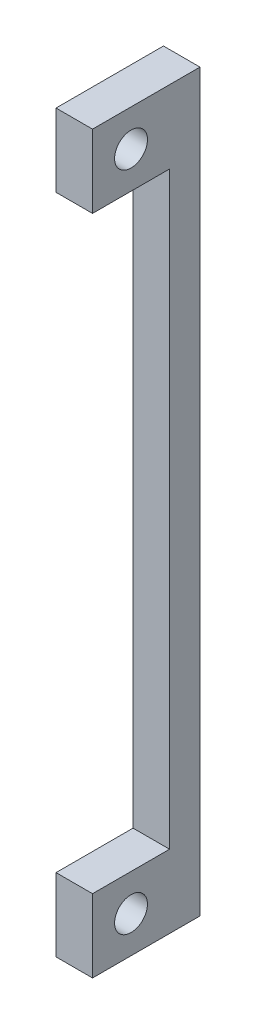
from build123d import *

# Parameters (mm, degrees)
SKICA2_W                 = 3
SKICA2_H                 = 60.4
P_IDAT_VYSUNUT_M1_DEPTH  = 2.5
SKICA2_3_W               = 3
SKICA2_3_H               = 6
P_IDAT_VYSUNUT_M2_DEPTH  = 8.8275
SKICA3_R                 = 1.35
ODEBRAT_VYSUNUT_M1_DEPTH = 8.8275


with BuildPart() as part:
    # Skica2 → P_idat vysunut_m1 (new body)
    with BuildSketch(Plane.XY):
        with Locations((-1.5, -30.2)):
            Rectangle(SKICA2_W, SKICA2_H)
    extrude(amount=P_IDAT_VYSUNUT_M1_DEPTH)

    # Skica2_3 → P_idat vysunut_m2 (add)
    with BuildSketch(Plane.XY):
        with Locations((-1.5, -3)):
            Rectangle(SKICA2_3_W, SKICA2_3_H)
        with Locations((-1.5, -57.4)):
            Rectangle(SKICA2_3_W, SKICA2_3_H)
    extrude(amount=P_IDAT_VYSUNUT_M2_DEPTH)

    # Skica3 → Odebrat vysunut_m1 (cut)
    with BuildSketch(Plane.ZY.offset(3)):
        with Locations((5.66375, -3)):
            Circle(SKICA3_R)
        with Locations((5.66375, -57.4)):
            Circle(SKICA3_R)
    extrude(amount=-ODEBRAT_VYSUNUT_M1_DEPTH, mode=Mode.SUBTRACT)


solid = part.part
